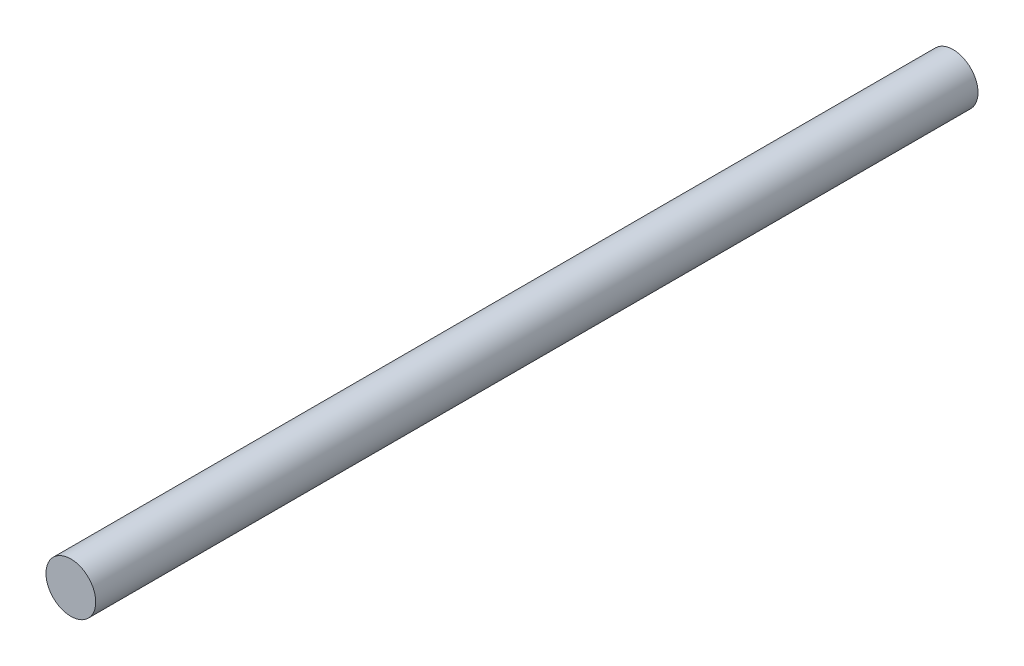
from build123d import *

# Parameters (mm, degrees)
SKETCH1_R           = 2.794
BOSS_EXTRUDE1_DEPTH = 99.06


with BuildPart() as part:
    # Sketch1 → Boss-Extrude1 (new body)
    with BuildSketch(Plane.XY):
        Circle(SKETCH1_R)
    extrude(amount=BOSS_EXTRUDE1_DEPTH)


solid = part.part
